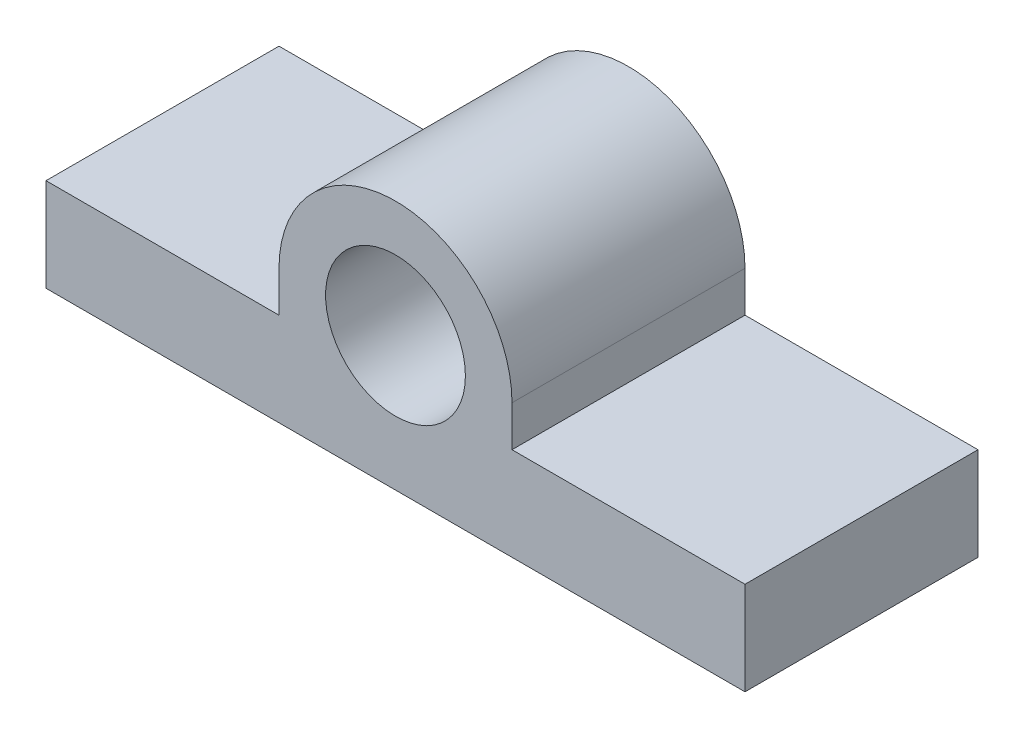
from build123d import *

# Parameters (mm, degrees)
SKETCH1_R           = 3.81
BOSS_EXTRUDE1_DEPTH = 12.7


with BuildPart() as part:
    # Sketch1 → Boss-Extrude1 (new body)
    with BuildSketch(Plane.XY):
        with BuildLine():
            Line((-21.102851537, -0.529390312), (-21.102851537, -5.609390312))
            Line((-21.102851537, -5.609390312), (16.997148463, -5.609390312))
            Line((16.997148463, -5.609390312), (16.997148463, -0.529390312))
            Line((16.997148463, -0.529390312), (4.297148463, -0.529390312))
            Line((4.297148463, -0.529390312), (4.297148463, 1.686095421))
            ThreePointArc((4.297148463, 1.686095421), (-2.052851537, 8.036095421), (-8.402851537, 1.686095421))
            Line((-8.402851537, 1.686095421), (-8.402851537, -0.529390312))
            Line((-8.402851537, -0.529390312), (-21.102851537, -0.529390312))
        make_face()
        with Locations((-2.052851537, 1.686095421)):
            Circle(SKETCH1_R, mode=Mode.SUBTRACT)
    extrude(amount=BOSS_EXTRUDE1_DEPTH)


solid = part.part
